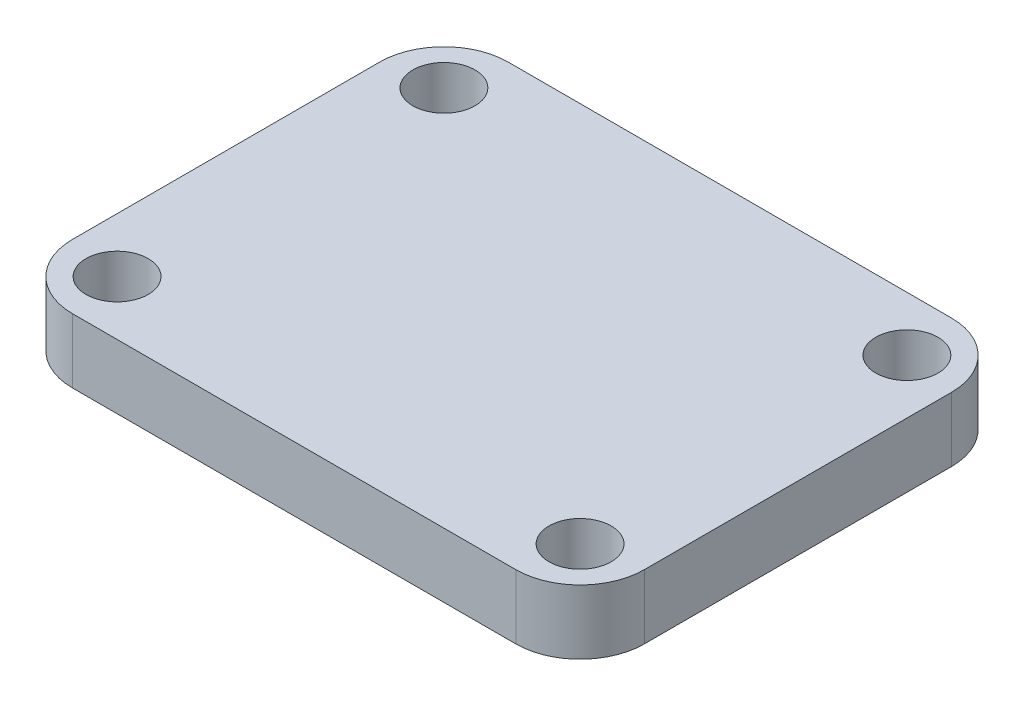
from build123d import *

# Parameters (mm, degrees)
SKETCH1_W           = 26.67
SKETCH1_H           = 20.32
SKETCH1_R           = 1.45
BOSS_EXTRUDE1_DEPTH = 3
FILLET1_R           = 3


with BuildPart() as part:
    # Sketch1 → Boss-Extrude1 (new body)
    with BuildSketch(Plane(origin=(0, 0, 0), x_dir=(1, 0, 0), z_dir=(0, 1, 0))):
        Rectangle(SKETCH1_W, SKETCH1_H)
        with Locations((-10.795, 7.62)):
            Circle(SKETCH1_R, mode=Mode.SUBTRACT)
        with Locations((-10.795, -7.62)):
            Circle(SKETCH1_R, mode=Mode.SUBTRACT)
        with Locations((10.795, -7.62)):
            Circle(SKETCH1_R, mode=Mode.SUBTRACT)
        with Locations((10.795, 7.62)):
            Circle(SKETCH1_R, mode=Mode.SUBTRACT)
    extrude(amount=BOSS_EXTRUDE1_DEPTH)

    # Fillet1
    fillet1_edges = [part.edges().sort_by_distance(p)[0] for p in [
        (13.335, 1.5, 10.16),
        (-13.335, 1.5, 10.16),
        (-13.335, 1.5, -10.16),
        (13.335, 1.5, -10.16),
    ]]
    fillet(fillet1_edges, radius=FILLET1_R)


solid = part.part
